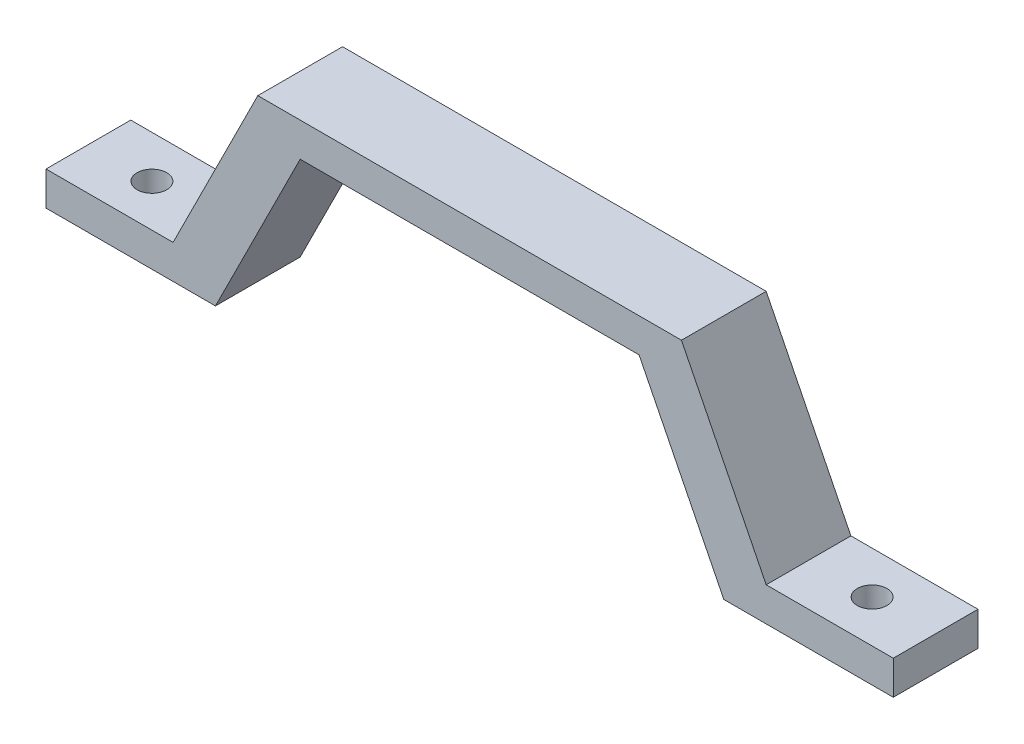
from build123d import *

# Parameters (mm, degrees)
BOSS_EXTRUDE1_DEPTH = 10
SKETCH2_R           = 1.75
CUT_EXTRUDE1_DEPTH  = 5


with BuildPart() as part:
    # Sketch1 → Boss-Extrude1 (new body)
    with BuildSketch(Plane.XY):
        Polygon((35, 4), (25, 24), (-25, 24), (-35, 4), (-50, 4), (-50, 0), (-30, 0), (-20, 20), (20, 20), (30, 0), (50, 0), (50, 4), align=None)
    extrude(amount=BOSS_EXTRUDE1_DEPTH)

    # Sketch2 → Cut-Extrude1 (cut, through all)
    with BuildSketch(Plane(origin=(0, 4, 0), x_dir=(1, 0, 0), z_dir=(0, 1, 0))):
        with Locations((42.5, -5)):
            Circle(SKETCH2_R)
        with Locations((-42.5, -5)):
            Circle(SKETCH2_R)
    extrude(amount=-CUT_EXTRUDE1_DEPTH, mode=Mode.SUBTRACT)


solid = part.part
